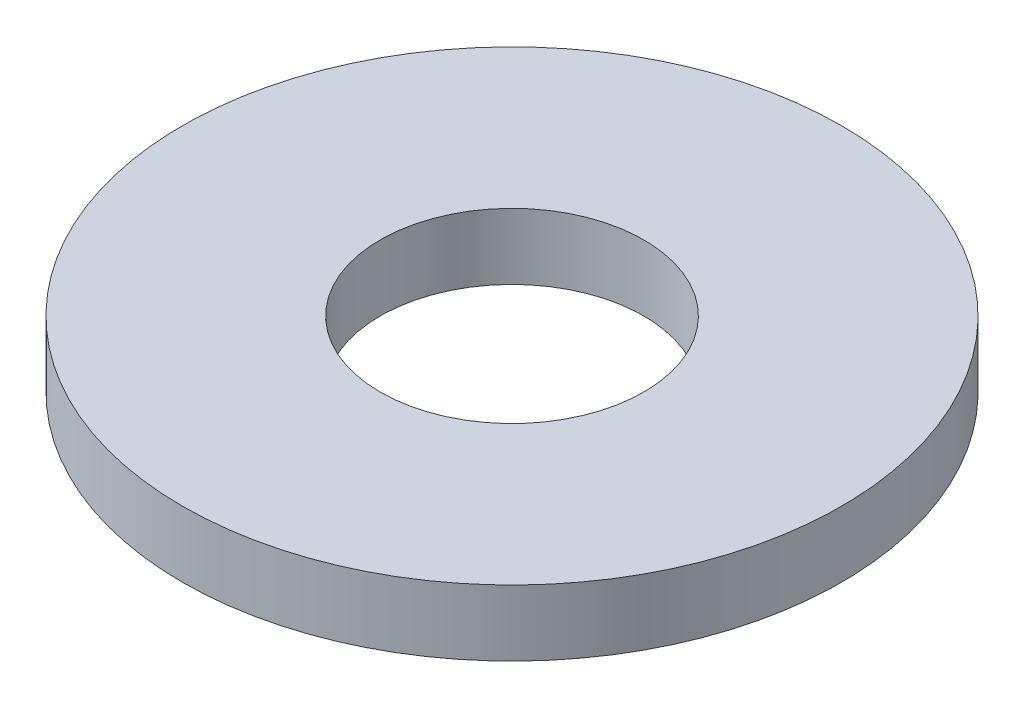
from build123d import *

# Parameters (mm, degrees)
SKETCH1_R           = 7.9375
SKETCH1_R_2         = 3.175
BOSS_EXTRUDE1_DEPTH = 1.5875


with BuildPart() as part:
    # Sketch1 → Boss-Extrude1 (new body)
    with BuildSketch(Plane(origin=(0, 0, 0), x_dir=(1, 0, 0), z_dir=(0, 1, 0))):
        Circle(SKETCH1_R)
        Circle(SKETCH1_R_2, mode=Mode.SUBTRACT)
    extrude(amount=BOSS_EXTRUDE1_DEPTH)


solid = part.part
